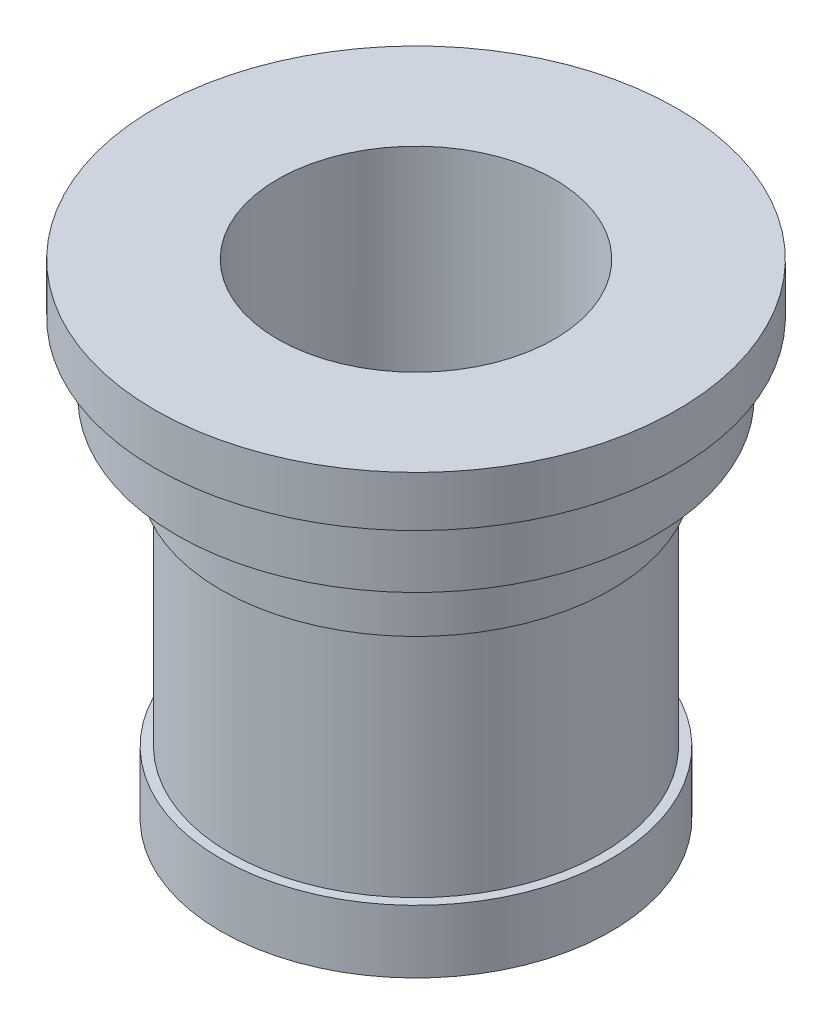
from build123d import *

# Parameters (mm, degrees)
SKETCH3_R          = 1.5
CUT_EXTRUDE1_DEPTH = 5


with BuildPart() as part:
    # Sketch2 → Revolve1 (revolve)
    with BuildSketch(Plane.XY, mode=Mode.PRIVATE) as revolve1_sk:
        Polygon((-22, 0), (-31, 0), (-31, 10), (-29.5, 10), (-29.5, 47), (-31, 47), (-31, 58), (-38, 58), (-38, 69), (-41.5, 69), (-41.5, 77), (-22, 77), align=None)
    revolve(revolve1_sk.sketch.rotate(Axis((0, 108.342465753, 0), (0, -1, 0)), 270), axis=Axis((0, 108.342465753, 0), (0, -1, 0)))  # turned: the seam where the file's is

    # Sketch3 → Cut-Extrude1 (cut)
    with BuildSketch(Plane.XZ):
        with Locations((-22, 0)):
            Circle(SKETCH3_R)
    extrude(amount=-CUT_EXTRUDE1_DEPTH, mode=Mode.SUBTRACT)


solid = part.part
